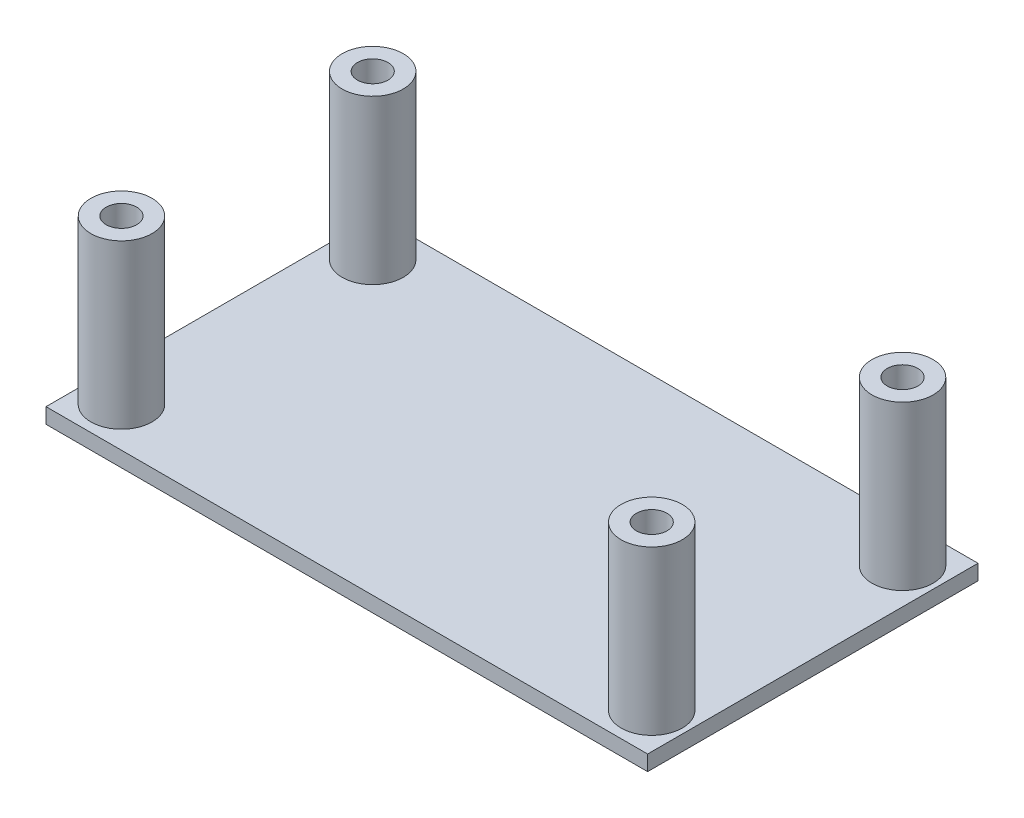
from build123d import *

# Parameters (mm, degrees)
SKETCH_2_W          = 57
SKETCH_2_H          = 40.4
EXTRUDE_1_DEPTH     = 1.5
SKETCH_4_R          = 3
SKETCH_4_R_2        = 1.5
EXTRUDE_3_DEPTH     = 16
SKETCH_5_W          = 57
SKETCH_5_H          = 4
CUT_EXTRUDE_1_DEPTH = 2.5
SKETCH_6_W          = 1
SKETCH_6_H          = 32.4
EXTRUDE_4_DEPTH     = 1.5


with BuildPart() as part:
    # 草图2 → 凸台-拉伸1 (new body)
    with BuildSketch(Plane(origin=(0, 0, 0), x_dir=(1, 0, 0), z_dir=(0, 1, 0))):
        with Locations((3.861898857, -4.534326193)):
            Rectangle(SKETCH_2_W, SKETCH_2_H)
    extrude(amount=EXTRUDE_1_DEPTH)

    # 草图4 → 凸台-拉伸3 (add)
    with BuildSketch(Plane(origin=(0, 1.5, 0), x_dir=(1, 0, 0), z_dir=(0, 1, 0))):
        with Locations((-22.099370277, 7.765673807)):
            Circle(SKETCH_4_R)
        with Locations((-22.099370277, 7.765673807)):
            Circle(SKETCH_4_R_2, mode=Mode.SUBTRACT)
        with Locations((-22.138101143, -16.834326193)):
            Circle(SKETCH_4_R)
        with Locations((-22.138101143, -16.834326193)):
            Circle(SKETCH_4_R_2, mode=Mode.SUBTRACT)
        with Locations((29.861898857, -16.834326193)):
            Circle(SKETCH_4_R)
        with Locations((29.861898857, -16.834326193)):
            Circle(SKETCH_4_R_2, mode=Mode.SUBTRACT)
        with Locations((29.861898857, 7.765673807)):
            Circle(SKETCH_4_R)
        with Locations((29.861898857, 7.765673807)):
            Circle(SKETCH_4_R_2, mode=Mode.SUBTRACT)
    extrude(amount=EXTRUDE_3_DEPTH)

    # 草图5 → 切除-拉伸1 (cut, through all)
    with BuildSketch(Plane(origin=(0, 1.5, 0), x_dir=(1, 0, 0), z_dir=(0, 1, 0))):
        with Locations((3.861898857, 13.665673807)):
            Rectangle(SKETCH_5_W, SKETCH_5_H)
        with Locations((3.861898857, -22.734326193)):
            Rectangle(SKETCH_5_W, SKETCH_5_H)
    extrude(amount=-CUT_EXTRUDE_1_DEPTH, mode=Mode.SUBTRACT)

    # 草图6 → 凸台-拉伸4 (add)
    with BuildSketch(Plane(origin=(0, 1.5, 0), x_dir=(1, 0, 0), z_dir=(0, 1, 0))):
        with Locations((-25.138101143, -4.534326193)):
            Rectangle(SKETCH_6_W, SKETCH_6_H)
        with Locations((32.861898857, -4.534326193)):
            Rectangle(SKETCH_6_W, SKETCH_6_H)
    extrude(amount=-EXTRUDE_4_DEPTH)


solid = part.part
